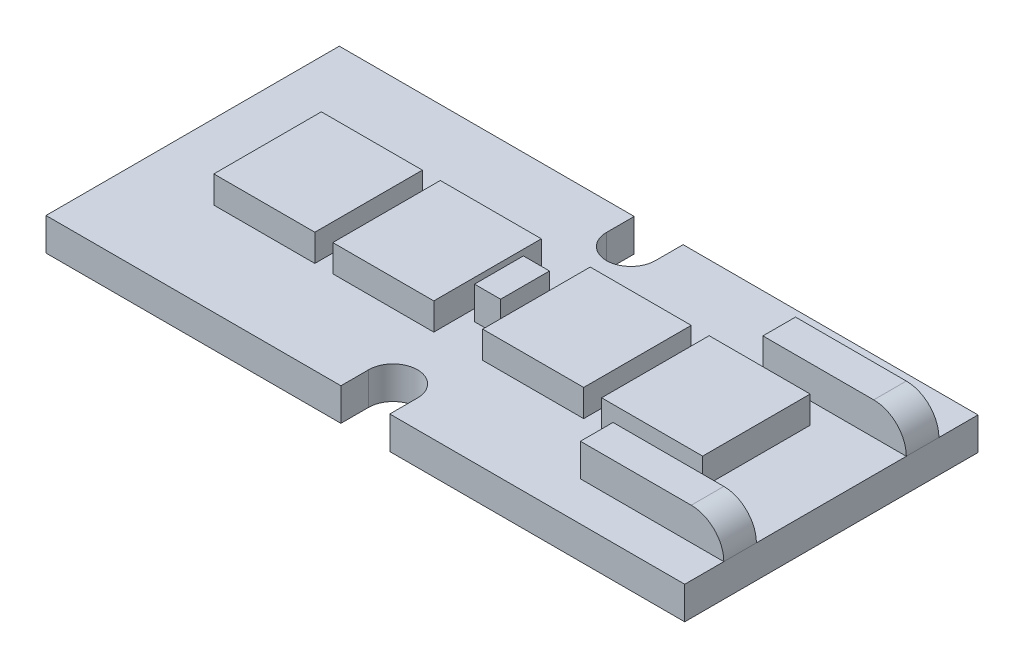
from build123d import *

# Parameters (mm, degrees)
EXTRUDE_1_DEPTH = 1
SKETCH_2_W      = 3.1
SKETCH_2_H      = 3.3
EXTRUDE_2_DEPTH = 0.83
SKETCH_3_W      = 4.4
SKETCH_3_H      = 1
SKETCH_3_W_2    = 0.8
SKETCH_3_H_2    = 1.5
EXTRUDE_3_DEPTH = 1
FILLET_1_R      = 1


with BuildPart() as part:
    # 草图1 → 凸台-拉伸1 (new body)
    with BuildSketch(Plane(origin=(0, 0, 0), x_dir=(1, 0, 0), z_dir=(0, 1, 0))):
        with BuildLine():
            Line((0, 0), (9.05, 0))
            Line((9.05, 0), (9.05, -0.85))
            ThreePointArc((9.05, -0.85), (9.8, -1.6), (10.55, -0.85))
            Line((10.55, -0.85), (10.55, 0))
            Line((10.55, 0), (19.6, 0))
            Line((19.6, 0), (19.6, -9))
            Line((19.6, -9), (10.55, -9))
            Line((10.55, -9), (10.55, -8.15))
            ThreePointArc((10.55, -8.15), (9.8, -7.4), (9.05, -8.15))
            Line((9.05, -8.15), (9.05, -9))
            Line((9.05, -9), (0, -9))
            Line((0, -9), (0, 0))
        make_face()
    extrude(amount=EXTRUDE_1_DEPTH)

    # 草图2 → 凸台-拉伸2 (add)
    with BuildSketch(Plane(origin=(0, 1, 0), x_dir=(1, 0, 0), z_dir=(0, 1, 0))):
        with Locations((3.85, -4.5)):
            Rectangle(SKETCH_2_W, SKETCH_2_H)
        with Locations((7.5, -4.5)):
            Rectangle(SKETCH_2_W, SKETCH_2_H)
        with Locations((12.1, -4.5)):
            Rectangle(SKETCH_2_W, SKETCH_2_H)
        with Locations((15.75, -4.5)):
            Rectangle(SKETCH_2_W, SKETCH_2_H)
    extrude(amount=EXTRUDE_2_DEPTH)

    # 草图3 → 凸台-拉伸3 (add)
    with BuildSketch(Plane(origin=(0, 1, 0), x_dir=(1, 0, 0), z_dir=(0, 1, 0))):
        with Locations((17.4, -7.3)):
            Rectangle(SKETCH_3_W, SKETCH_3_H)
        with Locations((9.8, -4.5)):
            Rectangle(SKETCH_3_W_2, SKETCH_3_H_2)
        with Locations((17.4, -1.7)):
            Rectangle(SKETCH_3_W, SKETCH_3_H)
    extrude(amount=EXTRUDE_3_DEPTH)

    # 圆角1
    fillet_1_edges = [part.edges().sort_by_distance(p)[0] for p in [
        (19.6, 2, 7.3),
        (19.6, 2, 1.7),
    ]]
    fillet(fillet_1_edges, radius=FILLET_1_R)


solid = part.part
